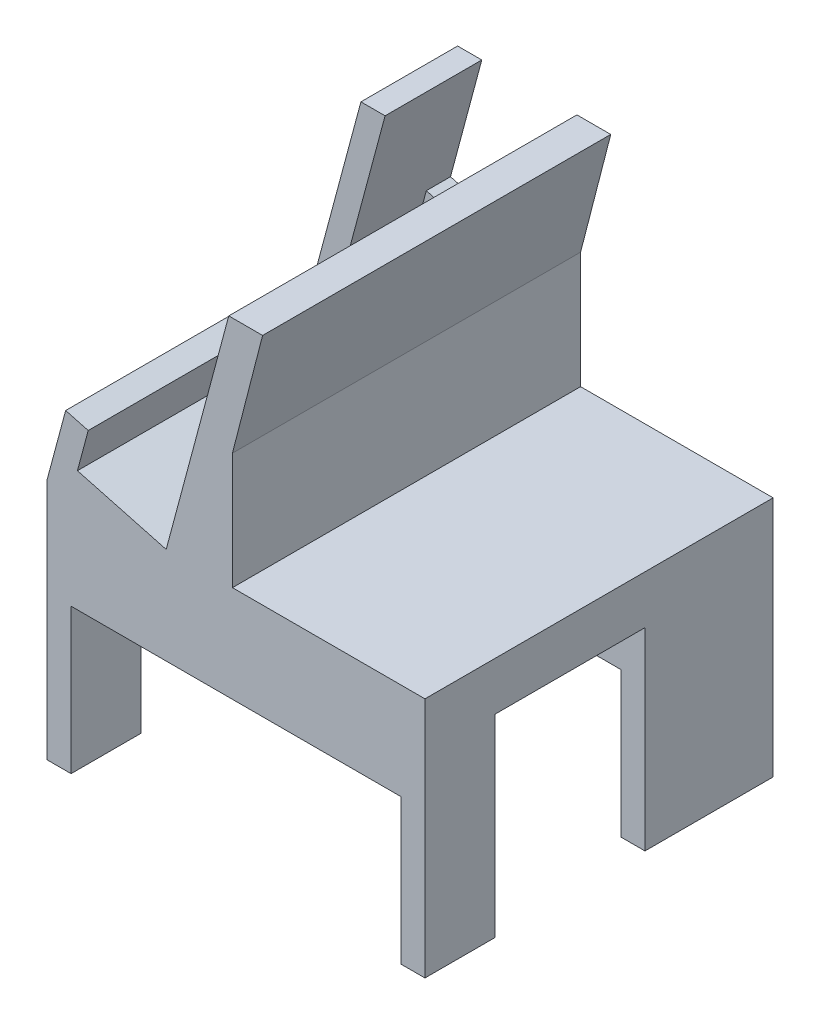
from build123d import *

# Parameters (mm, degrees)
EXTRUDE_1_DEPTH     = 72
SKETCH_2_W          = 68.186813186
SKETCH_2_H          = 31
CUT_EXTRUDE_1_DEPTH = 10
SKETCH_3_W          = 5
SKETCH_3_H          = 31
CUT_EXTRUDE_3_DEPTH = 40
SKETCH_4_W          = 5
SKETCH_4_H          = 31
CUT_EXTRUDE_4_DEPTH = 40
EXTRUDE_6_DEPTH     = 5
EXTRUDE_7_DEPTH     = 67
SKETCH_12_W         = 52
SKETCH_12_H         = 36.720454309
CUT_EXTRUDE_5_DEPTH = 5


with BuildPart() as part:
    # 草圖1 → 填料-伸長1 (new body)
    with BuildSketch(Plane.XY):
        Polygon((-56.41038016, 13.571428571), (-56.41038016, -36.428571429), (-51.41038016, -36.428571429), (-51.41038016, -6.428571429), (16.776433026, -6.428571429), (16.776433026, -36.428571429), (21.776433026, -36.428571429), (21.776433026, 13.571428571), align=None)
    extrude(amount=EXTRUDE_1_DEPTH)

    # 草圖2 → 除料-伸長1 (cut)
    with BuildSketch(Plane.XZ.offset(6.428571429)):
        with Locations((-17.316973567, 42)):
            Rectangle(SKETCH_2_W, SKETCH_2_H)
    extrude(amount=-CUT_EXTRUDE_1_DEPTH, mode=Mode.SUBTRACT)

    # 草圖3 → 除料-伸長3 (cut)
    with BuildSketch(Plane.XZ.offset(36.428571429)):
        with Locations((-53.91038016, 42)):
            Rectangle(SKETCH_3_W, SKETCH_3_H)
    extrude(amount=-CUT_EXTRUDE_3_DEPTH, mode=Mode.SUBTRACT)

    # 草圖4 → 除料-伸長4 (cut)
    with BuildSketch(Plane.XZ.offset(36.428571429)):
        with Locations((19.276433026, 42)):
            Rectangle(SKETCH_4_W, SKETCH_4_H)
    extrude(amount=-CUT_EXTRUDE_4_DEPTH, mode=Mode.SUBTRACT)

    # 草圖10 → 填料-伸長6 (add)
    with BuildSketch(Plane.XY):
        Polygon((-56.41038016, 13.571428571), (-43.469427905, 61.867719886), (-38.469427905, 61.867719886), (-44.939904033, 37.719574229), (-26.587313333, 32.802012372), (-18.799180477, 61.867719886), (-11.799180477, 61.867719886), (-18.038970236, 37.658939996), (-18.038970236, 13.571428571), align=None)
    extrude(amount=EXTRUDE_6_DEPTH)

    # 草圖11 → 填料-伸長7 (add)
    with BuildSketch(Plane.XY.offset(5)):
        Polygon((-43.469427905, 61.867719886), (-56.41038016, 13.571428571), (-31.740132733, 13.571428571), (-50.092723432, 18.488990428), (-44.939904033, 37.719574229), (-38.469427905, 61.867719886), align=None)
        Polygon((-26.587313333, 32.802012372), (-31.740132733, 13.571428571), (-18.038970236, 13.571428571), (-18.038970236, 37.658939996), (-11.799180477, 61.867719886), (-18.799180477, 61.867719886), align=None)
    extrude(amount=EXTRUDE_7_DEPTH)

    # 草圖12 → 除料-伸長5 (cut)
    with BuildSketch(Plane(origin=(-56.024458351, 15.011708372, 0), x_dir=(0, 0, 1), z_dir=(-0.965925826, 0.258819045, 0))):
        with Locations((46, 31.869139784)):
            Rectangle(SKETCH_12_W, SKETCH_12_H)
    extrude(amount=-CUT_EXTRUDE_5_DEPTH, mode=Mode.SUBTRACT)


solid = part.part
